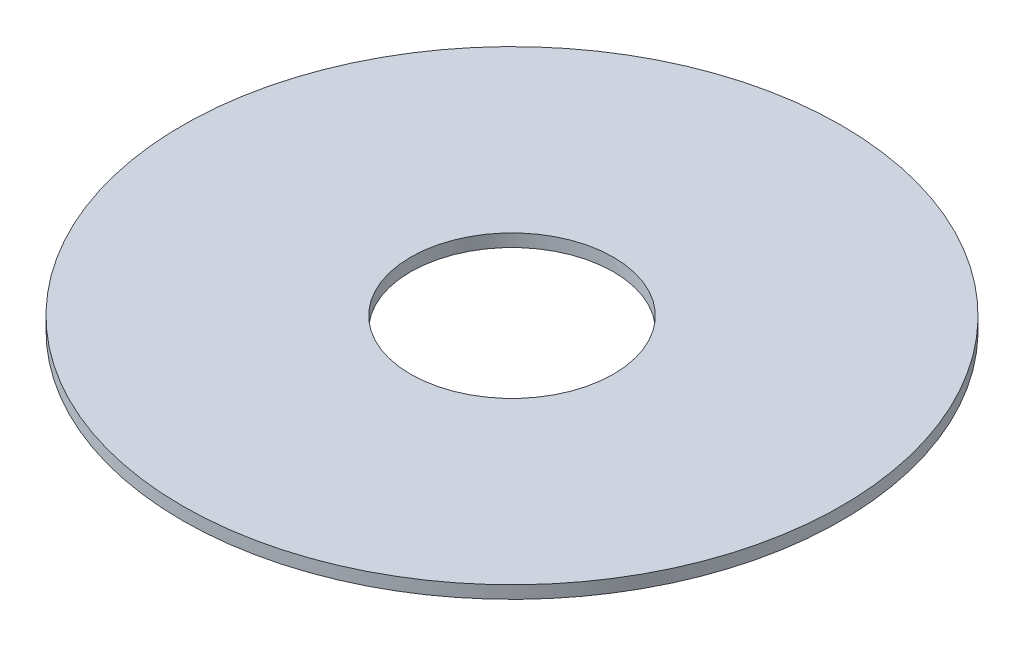
from build123d import *

# Parameters (mm, degrees)
SKETCH1_R           = 6.5
SKETCH1_R_2         = 2
BOSS_EXTRUDE1_DEPTH = 0.25


with BuildPart() as part:
    # Sketch1 → Boss-Extrude1 (new body)
    with BuildSketch(Plane(origin=(0, 0, 0), x_dir=(1, 0, 0), z_dir=(0, 1, 0))):
        Circle(SKETCH1_R)
        Circle(SKETCH1_R_2, mode=Mode.SUBTRACT)
    extrude(amount=BOSS_EXTRUDE1_DEPTH)


solid = part.part
